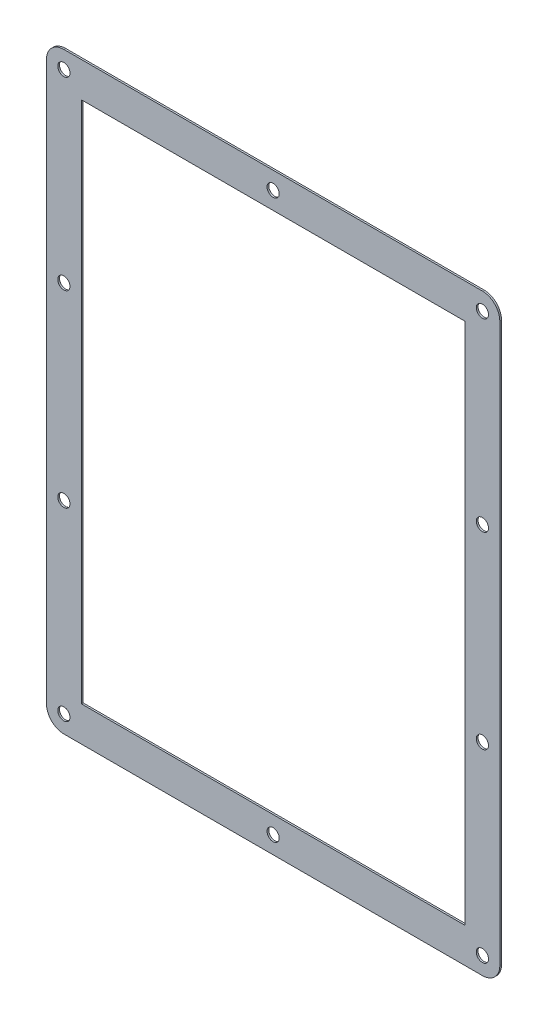
from build123d import *

# Parameters (mm, degrees)
SKETCH1_R           = 1.75
SKETCH1_W           = 110
SKETCH1_H           = 150
BOSS_EXTRUDE1_DEPTH = 0.5


with BuildPart() as part:
    # Sketch1 → Boss-Extrude1 (new body)
    with BuildSketch(Plane.XY):
        with BuildLine():
            Line((60, -85), (-60, -85))
            ThreePointArc((-60, -85), (-63.535533906, -83.535533906), (-65, -80))
            Line((-65, -80), (-65, 80))
            ThreePointArc((-65, 80), (-63.535533906, 83.535533906), (-60, 85))
            Line((-60, 85), (60, 85))
            ThreePointArc((60, 85), (63.535533906, 83.535533906), (65, 80))
            Line((65, 80), (65, -80))
            ThreePointArc((65, -80), (63.535533906, -83.535533906), (60, -85))
        make_face()
        with Locations((60, -27)):
            Circle(SKETCH1_R, mode=Mode.SUBTRACT)
        with Locations((60, -80)):
            Circle(SKETCH1_R, mode=Mode.SUBTRACT)
        with Locations(Location((-60, -27, 0), (0, 0, 180))):
            Circle(SKETCH1_R, mode=Mode.SUBTRACT)
        with Locations(Location((-60, -80, 0), (0, 0, 180))):
            Circle(SKETCH1_R, mode=Mode.SUBTRACT)
        with Locations((0, -80)):
            Circle(SKETCH1_R, mode=Mode.SUBTRACT)
        with Locations(Location((60, 27, 0), (0, 0, 180))):
            Circle(SKETCH1_R, mode=Mode.SUBTRACT)
        with Locations(Location((60, 80, 0), (0, 0, 180))):
            Circle(SKETCH1_R, mode=Mode.SUBTRACT)
        with Locations(Location((0, 80, 0), (0, 0, 180))):
            Circle(SKETCH1_R, mode=Mode.SUBTRACT)
        with Locations((-60, 27)):
            Circle(SKETCH1_R, mode=Mode.SUBTRACT)
        with Locations((-60, 80)):
            Circle(SKETCH1_R, mode=Mode.SUBTRACT)
        Rectangle(SKETCH1_W, SKETCH1_H, mode=Mode.SUBTRACT)
    extrude(amount=BOSS_EXTRUDE1_DEPTH)


solid = part.part
